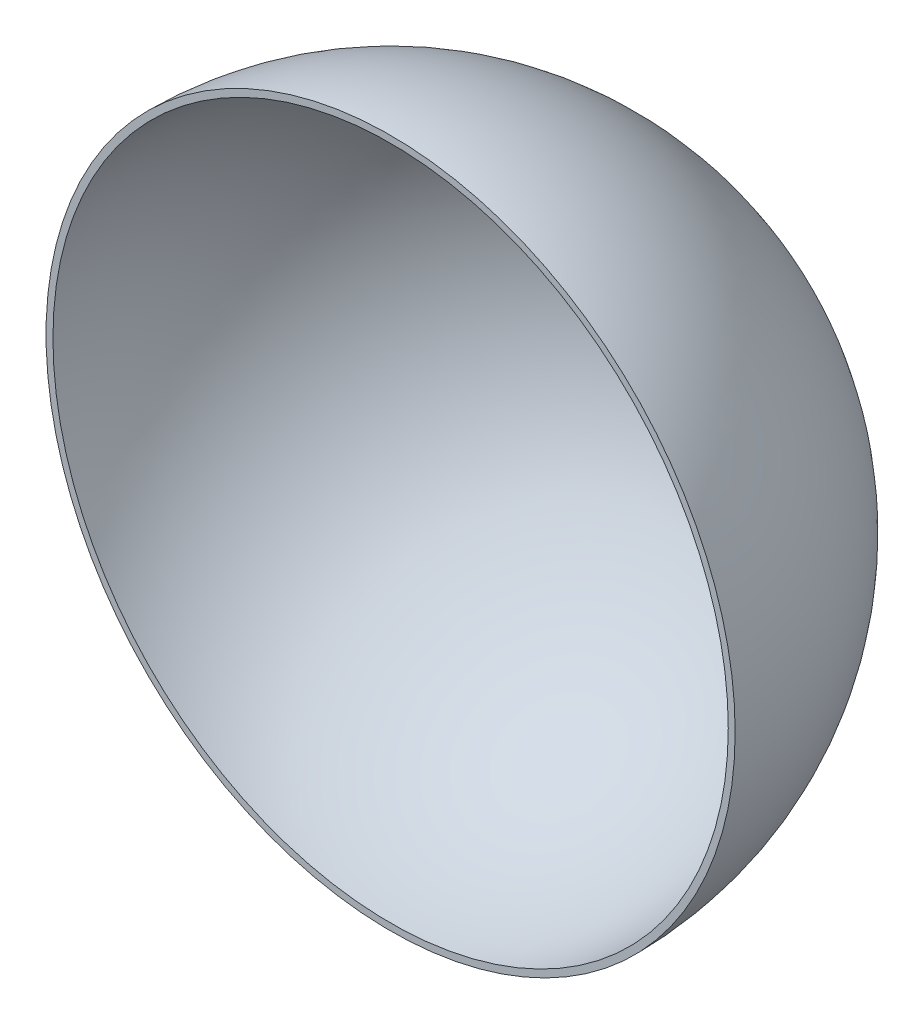
from build123d import *

# Parameters (mm, degrees)
SKETCH_2_R          = 100
CUT_EXTRUDE_1_DEPTH = 101


with BuildPart() as part:
    # 草图1 → 旋转7 (revolve)
    with BuildSketch(Plane.XY):
        with BuildLine():
            Line((0, 100), (0, -100))
            ThreePointArc((0, -100), (100, 0), (0, 100))
        make_face()
    revolve(axis=Axis((0, 100, 0), (0, -1, 0)))

    # 草图3 → 切除-旋转1 (revolve, cut)
    with BuildSketch(Plane.XY):
        with BuildLine():
            Line((0, 98), (0, -98))
            ThreePointArc((0, -98), (98, 0), (0, 98))
        make_face()
    revolve(axis=Axis((0, 98, 0), (0, -1, 0)), mode=Mode.SUBTRACT)

    # 草图2 → 切除-拉伸1 (cut, through all)
    with BuildSketch(Plane.XY):
        Circle(SKETCH_2_R)
    extrude(amount=CUT_EXTRUDE_1_DEPTH, mode=Mode.SUBTRACT)


solid = part.part
